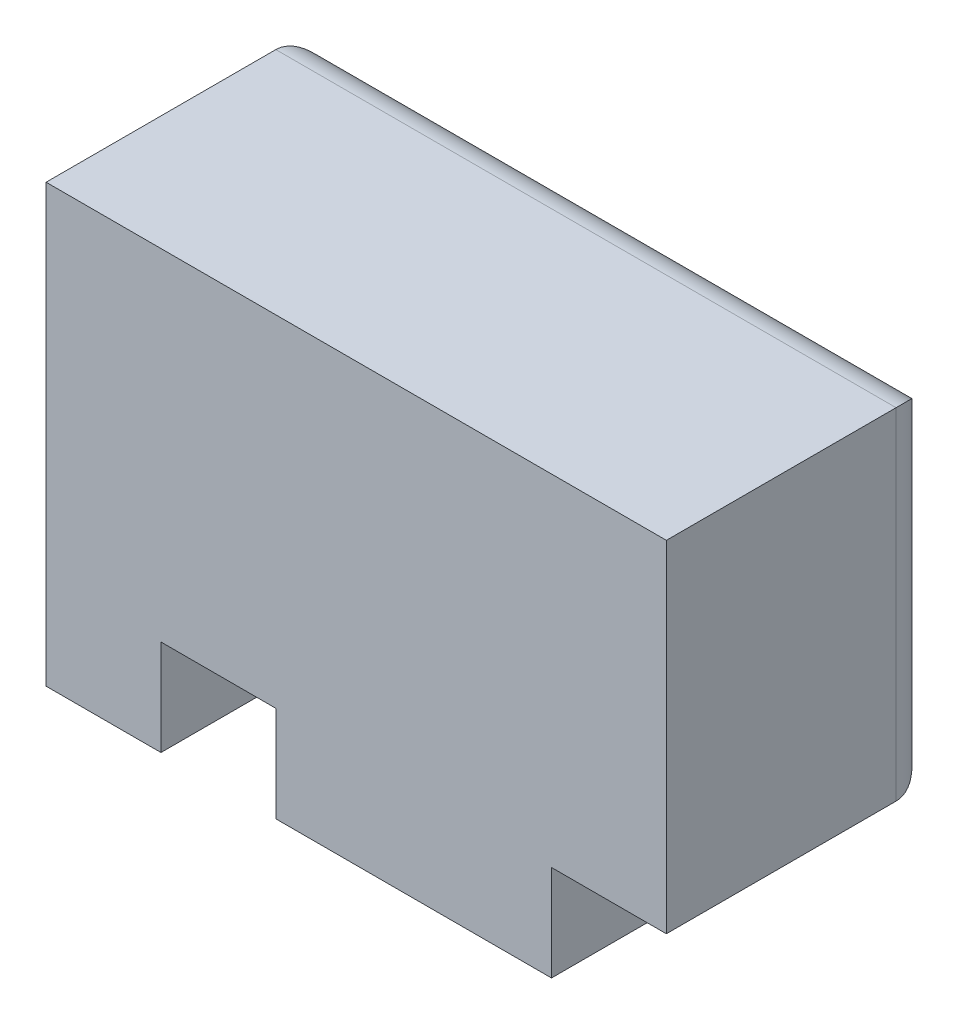
from build123d import *

# Parameters (mm, degrees)
SKICA1_W                 = 16.2
SKICA1_H                 = 11.4
P_IDAT_VYSUNUT_M1_DEPTH  = 7
SKICA2_W                 = 3
SKICA2_H                 = 2.5
ODEBRAT_VYSUNUT_M1_DEPTH = 8
ZAOBLIT5_R               = 1


with BuildPart() as part:
    # Skica1 → Přidat vysunutím1 (new body)
    with BuildSketch(Plane.XY):
        with Locations((8.1, 5.7)):
            Rectangle(SKICA1_W, SKICA1_H)
    extrude(amount=P_IDAT_VYSUNUT_M1_DEPTH)

    # Skica2 → Odebrat vysunutím1 (cut, through all)
    with BuildSketch(Plane.XY.offset(7)):
        with Locations((4.5, 1.25)):
            Rectangle(SKICA2_W, SKICA2_H)
        with Locations((14.7, 1.25)):
            Rectangle(SKICA2_W, SKICA2_H)
    extrude(amount=-ODEBRAT_VYSUNUT_M1_DEPTH, mode=Mode.SUBTRACT)

    # Zaoblit5
    zaoblit5_edges = [part.edges().sort_by_distance(p)[0] for p in [
        (16.2, 6.95, 0),
        (9.6, 0, 0),
        (6, 1.25, 0),
        (3, 1.25, 0),
        (4.5, 2.5, 0),
        (14.7, 2.5, 0),
        (13.2, 1.25, 0),
        (8.1, 11.4, 0),
        (1.5, 0, 0),
        (0, 5.7, 0),
    ]]
    fillet(zaoblit5_edges, radius=ZAOBLIT5_R)


solid = part.part
